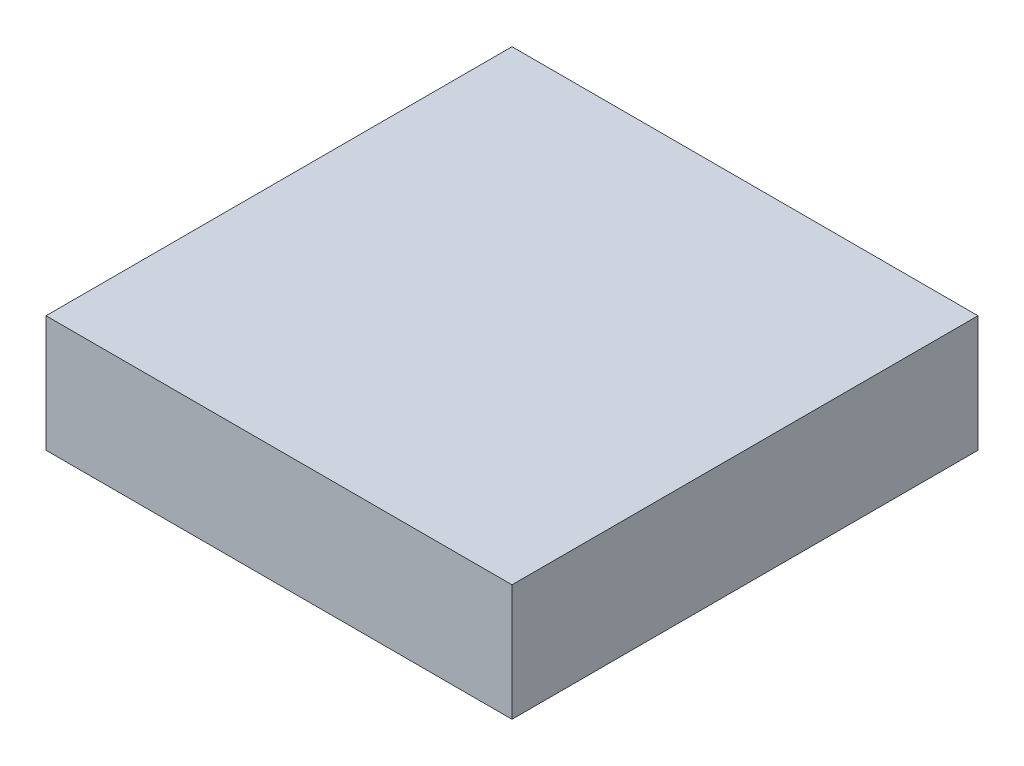
from build123d import *

# Parameters (mm, degrees)
SKETCH1_W           = 25.4
SKETCH1_H           = 25.4
BOSS_EXTRUDE1_DEPTH = 6.35


with BuildPart() as part:
    # Sketch1 → Boss-Extrude1 (new body)
    with BuildSketch(Plane(origin=(0, 0, 0), x_dir=(1, 0, 0), z_dir=(0, 1, 0))):
        Rectangle(SKETCH1_W, SKETCH1_H)
    extrude(amount=BOSS_EXTRUDE1_DEPTH)


solid = part.part
